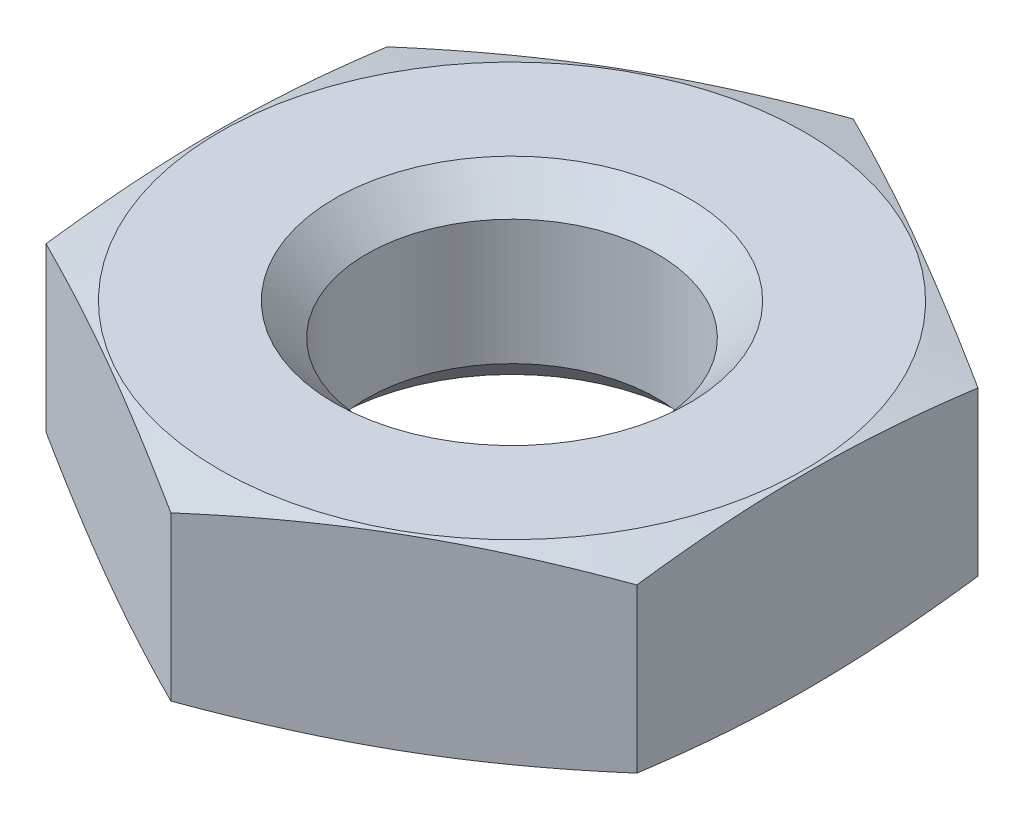
from build123d import *

# Parameters (mm, degrees)
CUT_EXTRUDE1_DEPTH      = 4.2
CUT_EXTRUDE1_DEPTH_BACK = 4.2
SKETCH2_W               = 40
SKETCH2_H               = 40


with BuildPart() as part:
    # Sketch1 → Revolve1 (revolve)
    with BuildSketch(Plane.XY):
        Polygon((0, 0), (4.95, 0), (10.921281292, -1.6), (4.95, -3.2), (0, -3.2), align=None)
    revolve(axis=Axis((0, -3.2, 0), (0, 1, 0)))

    # Sketch2 → Cut-Extrude1 (cut, two sides: drawn at the far end of the back side and taken through both)
    with BuildSketch(Plane(origin=(0, 0, 0), x_dir=(1, 0, 0), z_dir=(0, 1, 0)).offset(-CUT_EXTRUDE1_DEPTH_BACK)):
        Rectangle(SKETCH2_W, SKETCH2_H)
        Polygon((-5, -2.886751346), (0, -5.773502692), (5, -2.886751346), (5, 2.886751346), (0, 5.773502692), (-5, 2.886751346), align=None, mode=Mode.SUBTRACT)
    extrude(amount=CUT_EXTRUDE1_DEPTH + CUT_EXTRUDE1_DEPTH_BACK, mode=Mode.SUBTRACT)

    # Sketch3 → Cut-Revolve1 (revolve, cut)
    with BuildSketch(Plane.XY):
        Polygon((0, 0), (3, 0), (2.4585, -0.5415), (2.4585, -2.6585), (3, -3.2), (0, -3.2), align=None)
    revolve(axis=Axis((0, -3.2, 0), (0, 1, 0)), mode=Mode.SUBTRACT)


solid = part.part
